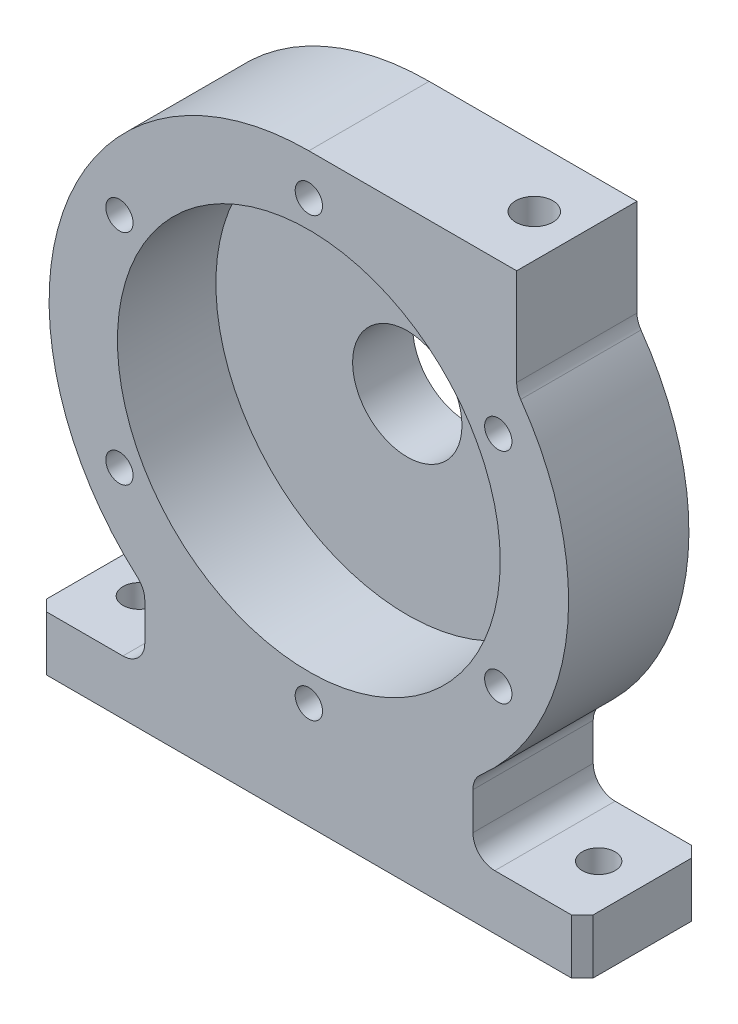
from build123d import *

# Parameters (mm, degrees)
BOSS_EXTRUDE1_DEPTH                                 = 22
SKETCH3_R                                           = 35
CUT_EXTRUDE1_DEPTH                                  = 18
SKETCH4_R                                           = 14
BOSS_EXTRUDE2_DEPTH                                 = 7
FILLET1_R                                           = 4
SKETCH5_R                                           = 10
CUT_EXTRUDE2_DEPTH                                  = 30
CHAMFER1_SIZE                                       = 2
M8X1_25_TAPPED_HOLE1_D                              = 6.8
M8X1_25_TAPPED_HOLE1_DEPTH                          = 29.75
M8X1_25_TAPPED_HOLE1_TIP                            = 2.042926105
CIRPATTERN1_COUNT                                   = 6
CSK_FOR_M6_COUNTERSUNK_FLAT_HEAD_SCREW2_D           = 6
CSK_FOR_M6_COUNTERSUNK_FLAT_HEAD_SCREW2_DEPTH       = 20
CSK_FOR_M6_COUNTERSUNK_FLAT_HEAD_SCREW2_CSINK_D     = 8
CSK_FOR_M6_COUNTERSUNK_FLAT_HEAD_SCREW2_CSINK_ANGLE = 90
CSK_FOR_M6_COUNTERSUNK_FLAT_HEAD_SCREW2_TIP         = 1.802581857


with BuildPart() as part:
    # Sketch2 → Boss-Extrude1 (new body)
    with BuildSketch(Plane.XY):
        with BuildLine():
            Line((-50, -59.5), (50, -59.5))
            Line((50, -59.5), (50, -49.5))
            Line((50, -49.5), (34, -49.5))
            ThreePointArc((34, -49.5), (31.171572875, -48.328427125), (30, -45.5))
            Line((30, -45.5), (30, -38.681390875))
            ThreePointArc((30, -38.681390875), (30.35561344, -37.032619635), (31.359223301, -35.677011001))
            ThreePointArc((31.359223301, -35.677011001), (47.179198283, -5.511193099), (38.737864078, 27.488686522))
            ThreePointArc((38.737864078, 27.488686522), (38.18892773, 28.588727762), (38, 29.803523282))
            Line((38, 29.803523282), (38, 47.5))
            Line((38, 47.5), (0, 47.5))
            ThreePointArc((0, 47.5), (-44.446079819, 16.756968363), (-31.359223301, -35.677011001))
            ThreePointArc((-31.359223301, -35.677011001), (-30.35561344, -37.032619635), (-30, -38.681390875))
            Line((-30, -38.681390875), (-30, -45.5))
            ThreePointArc((-30, -45.5), (-31.171572875, -48.328427125), (-34, -49.5))
            Line((-34, -49.5), (-50, -49.5))
            Line((-50, -49.5), (-50, -59.5))
        make_face()
    extrude(amount=BOSS_EXTRUDE1_DEPTH)

    # Sketch3 → Cut-Extrude1 (cut)
    with BuildSketch(Plane.XY.offset(22)):
        Circle(SKETCH3_R)
    extrude(amount=-CUT_EXTRUDE1_DEPTH, mode=Mode.SUBTRACT)

    # Sketch4 → Boss-Extrude2 (add)
    with BuildSketch(Plane(origin=(0, 0, 0), x_dir=(-1, 0, 0), z_dir=(0, 0, -1))):
        Circle(SKETCH4_R)
    extrude(amount=BOSS_EXTRUDE2_DEPTH)

    # Fillet1
    fillet1_edges = [part.edges().sort_by_distance(p)[0] for p in [
        (14, 0, 0),
    ]]
    fillet(fillet1_edges, radius=FILLET1_R)

    # Sketch5 → Cut-Extrude2 (cut, through all)
    with BuildSketch(Plane(origin=(0, 0, -7), x_dir=(-1, 0, 0), z_dir=(0, 0, -1))):
        Circle(SKETCH5_R)
    extrude(amount=-CUT_EXTRUDE2_DEPTH, mode=Mode.SUBTRACT)

    # Chamfer1
    chamfer1_edges = [part.edges().sort_by_distance(p)[0] for p in [
        (50, -54.5, 0),
        (-50, -54.5, 0),
        (-50, -54.5, 22),
        (50, -54.5, 22),
    ]]
    chamfer(chamfer1_edges, length=CHAMFER1_SIZE)

    # M8x1.25 Tapped Hole1
    with Locations(Plane(origin=(30.22415, 47.5, 11), x_dir=(0, 0, 1), z_dir=(0, 1, 0))):
        with Locations((0, 0)):
            Hole(M8X1_25_TAPPED_HOLE1_D / 2, depth=M8X1_25_TAPPED_HOLE1_DEPTH)
            with Locations((0, 0, -(M8X1_25_TAPPED_HOLE1_DEPTH + M8X1_25_TAPPED_HOLE1_TIP / 2))):  # 118° drill point
                Cone(0, M8X1_25_TAPPED_HOLE1_D / 2, M8X1_25_TAPPED_HOLE1_TIP, mode=Mode.SUBTRACT)

    # Sketch11 → M6x1.0 Tapped Hole1 (revolve, cut)
    with BuildSketch(Plane(origin=(0, 40, 22), x_dir=(0, -1, 0), z_dir=(1, 0, 0))):
        Polygon((0, 0), (0, 16.502151548), (2.5, 15), (2.5, 0), align=None)
    m6x1_0_tapped_hole1 = revolve(axis=Axis((0, 40, 28.35), (0, 0, -1)), mode=Mode.SUBTRACT)

    # CirPattern1: M6x1.0 Tapped Hole1 ×6 about axis
    cirpattern1_axis = Axis((0, 0, 0), (0, 0, 1))
    for i in range(1, CIRPATTERN1_COUNT):
        add(m6x1_0_tapped_hole1.rotate(cirpattern1_axis, i * 360 / CIRPATTERN1_COUNT), mode=Mode.SUBTRACT)

    # CSK for M6 Countersunk Flat Head Screw2
    with Locations(Plane(origin=(0, -59.5, 0), x_dir=(-1, 0, 0), z_dir=(0, -1, 0))):
        with Locations((-42, -11), (42, -11)):
            CounterSinkHole(CSK_FOR_M6_COUNTERSUNK_FLAT_HEAD_SCREW2_D / 2, CSK_FOR_M6_COUNTERSUNK_FLAT_HEAD_SCREW2_CSINK_D / 2, depth=CSK_FOR_M6_COUNTERSUNK_FLAT_HEAD_SCREW2_DEPTH, counter_sink_angle=CSK_FOR_M6_COUNTERSUNK_FLAT_HEAD_SCREW2_CSINK_ANGLE)
            with Locations((0, 0, -(CSK_FOR_M6_COUNTERSUNK_FLAT_HEAD_SCREW2_DEPTH + CSK_FOR_M6_COUNTERSUNK_FLAT_HEAD_SCREW2_TIP / 2))):  # 118° drill point
                Cone(0, CSK_FOR_M6_COUNTERSUNK_FLAT_HEAD_SCREW2_D / 2, CSK_FOR_M6_COUNTERSUNK_FLAT_HEAD_SCREW2_TIP, mode=Mode.SUBTRACT)


solid = part.part
